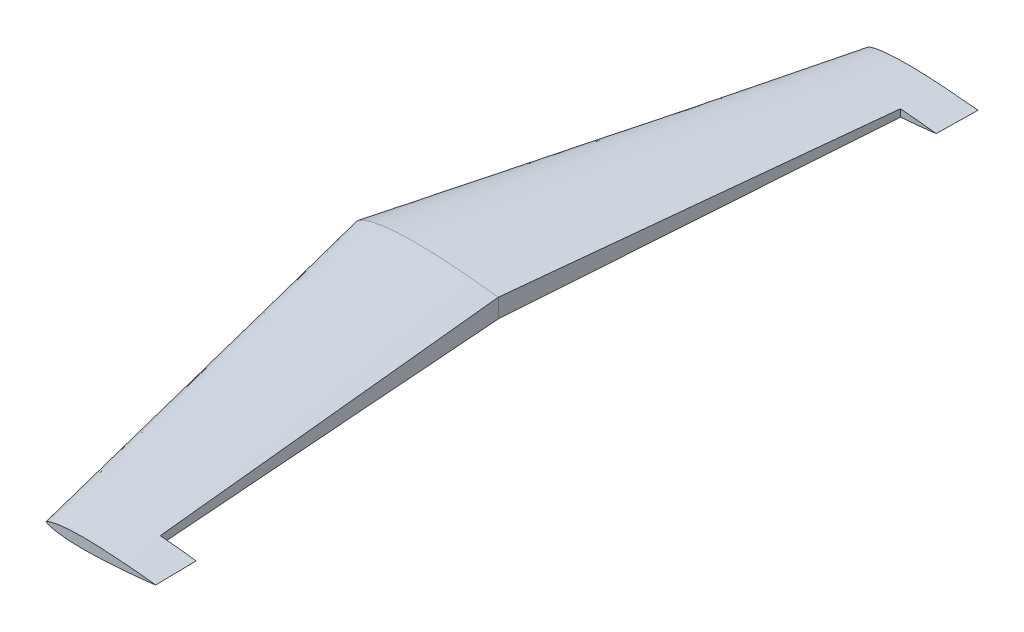
from build123d import *

# Parameters (mm, degrees)
CUT_EXTRUDE1_DEPTH      = 338.86333719
CUT_EXTRUDE1_DEPTH_BACK = 338.86333719


with BuildPart() as part:
    # Sketch7 → Loft1 section 0
    with BuildSketch(Plane.XY.offset(-300)):
        with BuildLine():
            add(Edge.make_bspline(
                [(75, 0), (75.206475425, 0.096371722), (76.3351457, 0.581391278), (78.368129782, 1.199474072), (81.277489522, 1.836292239), (85.603806113, 2.529055956), (93.292769423, 3.236411315), (104.872391196, 3.45907425), (119.123385393, 2.991621898), (132.921299844, 2.092884069), (142.797437906, 1.246534379), (148.566713359, 0.688863299), (151.71230792, 0.363797013), (153.838167507, 0.146487283), (155, 0)],
                knots=[0.041089257, 0.041089257, 0.041089257, 0.041089257, 0.048950772, 0.083424122, 0.114483795, 0.151867659, 0.23485952, 0.381272081, 0.552057215, 0.727745971, 0.859296949, 0.894761026, 0.928143313, 0.968636452, 0.968636452, 0.968636452, 0.968636452], degree=3))
            add(Edge.make_bspline(
                [(75, 0), (75.206475425, -0.096371722), (76.3351457, -0.581391278), (78.368129782, -1.199474072), (81.277489522, -1.836292239), (85.603806113, -2.529055956), (93.292769423, -3.236411315), (104.872391196, -3.45907425), (119.123385393, -2.991621898), (132.921299844, -2.092884069), (142.797437905, -1.246534379), (148.566713359, -0.688863299), (151.71230792, -0.363797013), (153.838167507, -0.146487283), (155, 0)],
                knots=[0.041089257, 0.041089257, 0.041089257, 0.041089257, 0.048950772, 0.083424122, 0.114483795, 0.151867659, 0.23485952, 0.381272081, 0.552057215, 0.727745971, 0.859296949, 0.894761026, 0.928143313, 0.968636452, 0.968636452, 0.968636452, 0.968636452], degree=3))
        make_face()
    # Sketch5 → Loft1 section 1
    with BuildSketch(Plane.XY):
        with BuildLine():
            add(Edge.make_bspline(
                [(0, 0), (0.357433553, 1.567842951), (1.917970176, 4.160229764), (5.97481653, 6.081249697), (9.685317154, 7.498428782), (13.560078119, 8.488450032), (17.359013279, 9.274437737), (21.537080113, 9.926762724), (26.46178465, 10.495714484), (33.030088427, 11.004191676), (39.777903449, 11.237535202), (48.881830343, 11.276440135), (58.76193613, 11.001555412), (68.683481214, 10.411026067), (82.689863985, 9.343738865), (94.136580366, 8.168132094), (108.892414504, 6.408281033), (116.550975745, 5.416254952), (123.975633155, 4.354289335), (127.960081342, 3.77052037), (132.393799107, 3.105793902), (137.115401047, 2.40243394), (143.03529364, 1.468316053), (147.203728737, 0.596703087), (150, 0)],
                knots=[0, 0, 0, 0, 0.031271315, 0.055076604, 0.085653186, 0.108857761, 0.132714605, 0.161157924, 0.191102095, 0.229169149, 0.289322728, 0.322456152, 0.406317058, 0.481621487, 0.515848821, 0.679661265, 0.705502791, 0.805025067, 0.829931294, 0.851453308, 0.883388416, 0.917173131, 0.944349664, 1, 1, 1, 1], degree=3))
            add(Edge.make_bspline(
                [(0, 0), (0.394064241, -1.54877785), (1.863432045, -4.108329327), (5.28724909, -5.736171), (8.233222924, -6.999318685), (11.439608234, -7.961073986), (14.837636919, -8.774678376), (18.226738528, -9.412867336), (21.607899865, -9.923992079), (25.17739935, -10.35155024), (30.263863608, -10.813990829), (36.567415813, -11.154786303), (45.633644275, -11.313399436), (54.659951216, -11.138633145), (65.729134774, -10.617890693), (80.628353886, -9.553465623), (94.39151788, -8.136116187), (108.235367187, -6.487796867), (115.481434177, -5.556138542), (124.038094924, -4.350742236), (129.185840061, -3.589034499), (134.229817914, -2.830310801), (137.671437841, -2.315360587), (140.909856219, -1.801519139), (145.017744862, -1.058252808), (147.972088501, -0.42879218), (150, 0)],
                knots=[0, 0, 0, 0, 0.031458743, 0.053377779, 0.072332266, 0.094059262, 0.118322991, 0.140338064, 0.161137525, 0.18485863, 0.210283619, 0.260514048, 0.30767032, 0.386712656, 0.436156502, 0.523300177, 0.677353161, 0.705359806, 0.794596405, 0.819513727, 0.8735115, 0.895859044, 0.9187711, 0.941229566, 0.959662244, 1, 1, 1, 1], degree=3))
        make_face()
    loft()

    # Sketch5_3 → Loft2 section 0
    with BuildSketch(Plane.XY):
        with BuildLine():
            add(Edge.make_bspline(
                [(0, 0), (0.357433553, 1.567842951), (1.917970176, 4.160229764), (5.97481653, 6.081249697), (9.685317154, 7.498428782), (13.560078119, 8.488450032), (17.359013279, 9.274437737), (21.537080113, 9.926762724), (26.46178465, 10.495714484), (33.030088427, 11.004191676), (39.777903449, 11.237535202), (48.881830343, 11.276440135), (58.76193613, 11.001555412), (68.683481214, 10.411026067), (82.689863985, 9.343738865), (94.136580366, 8.168132094), (108.892414504, 6.408281033), (116.550975745, 5.416254952), (123.975633155, 4.354289335), (127.960081342, 3.77052037), (132.393799107, 3.105793902), (137.115401047, 2.40243394), (143.03529364, 1.468316053), (147.203728737, 0.596703087), (150, 0)],
                knots=[0, 0, 0, 0, 0.031271315, 0.055076604, 0.085653186, 0.108857761, 0.132714605, 0.161157924, 0.191102095, 0.229169149, 0.289322728, 0.322456152, 0.406317058, 0.481621487, 0.515848821, 0.679661265, 0.705502791, 0.805025067, 0.829931294, 0.851453308, 0.883388416, 0.917173131, 0.944349664, 1, 1, 1, 1], degree=3))
            add(Edge.make_bspline(
                [(0, 0), (0.394064241, -1.54877785), (1.863432045, -4.108329327), (5.28724909, -5.736171), (8.233222924, -6.999318685), (11.439608234, -7.961073986), (14.837636919, -8.774678376), (18.226738528, -9.412867336), (21.607899865, -9.923992079), (25.17739935, -10.35155024), (30.263863608, -10.813990829), (36.567415813, -11.154786303), (45.633644275, -11.313399436), (54.659951216, -11.138633145), (65.729134774, -10.617890693), (80.628353886, -9.553465623), (94.39151788, -8.136116187), (108.235367187, -6.487796867), (115.481434177, -5.556138542), (124.038094924, -4.350742236), (129.185840061, -3.589034499), (134.229817914, -2.830310801), (137.671437841, -2.315360587), (140.909856219, -1.801519139), (145.017744862, -1.058252808), (147.972088501, -0.42879218), (150, 0)],
                knots=[0, 0, 0, 0, 0.031458743, 0.053377779, 0.072332266, 0.094059262, 0.118322991, 0.140338064, 0.161137525, 0.18485863, 0.210283619, 0.260514048, 0.30767032, 0.386712656, 0.436156502, 0.523300177, 0.677353161, 0.705359806, 0.794596405, 0.819513727, 0.8735115, 0.895859044, 0.9187711, 0.941229566, 0.959662244, 1, 1, 1, 1], degree=3))
        make_face()
    # Sketch6 → Loft2 section 1
    with BuildSketch(Plane.XY.offset(300)):
        with BuildLine():
            add(Edge.make_bspline(
                [(75, 0), (75.120883083, 0.088220679), (75.706824811, 0.476470131), (77.217776324, 1.174259893), (79.48323534, 1.851270283), (82.263977956, 2.446094236), (86.397882391, 3.087901728), (93.742502034, 3.72837444), (104.799714721, 3.888399612), (118.404415718, 3.377375586), (131.574558905, 2.456618013), (141.000434992, 1.603685916), (146.506396783, 1.045029323), (150.297395847, 0.6350389), (153.115725967, 0.334622173), (155, 0)],
                knots=[0.023529753, 0.023529753, 0.023529753, 0.023529753, 0.028948177, 0.048950772, 0.083424122, 0.114483795, 0.151867659, 0.23485952, 0.381272081, 0.552057215, 0.727745971, 0.859296949, 0.894761026, 0.928143313, 0.997376672, 0.997376672, 0.997376672, 0.997376672], degree=3))
            add(Edge.make_bspline(
                [(75, 0), (75.120883083, -0.088220679), (75.706824811, -0.476470131), (77.217776323, -1.174259893), (79.48323534, -1.851270283), (82.263977955, -2.446094236), (86.397882391, -3.087901728), (93.742502034, -3.72837444), (104.799714721, -3.888399612), (118.404415718, -3.377375586), (131.574558905, -2.456618013), (141.000434992, -1.603685916), (146.506396783, -1.045029323), (150.297395847, -0.6350389), (153.115725967, -0.334622173), (155, 0)],
                knots=[0.023529753, 0.023529753, 0.023529753, 0.023529753, 0.028948177, 0.048950772, 0.083424122, 0.114483795, 0.151867659, 0.23485952, 0.381272081, 0.552057215, 0.727745971, 0.859296949, 0.894761026, 0.928143313, 0.997376672, 0.997376672, 0.997376672, 0.997376672], degree=3))
        make_face()
    loft()

    # Sketch10 → Cut-Extrude1 (cut, two sides: drawn at the far end of the back side and taken through both)
    with BuildSketch(Plane(origin=(0, 0, 0), x_dir=(1, 0, 0), z_dir=(0, 1, 0)).offset(-CUT_EXTRUDE1_DEPTH_BACK)):
        Polygon((154.5, 270), (128.4, 270), (105, 0), (128.4, -270), (154.5, -270), (150, 0), align=None)
    extrude(amount=CUT_EXTRUDE1_DEPTH + CUT_EXTRUDE1_DEPTH_BACK, mode=Mode.SUBTRACT)


solid = part.part
